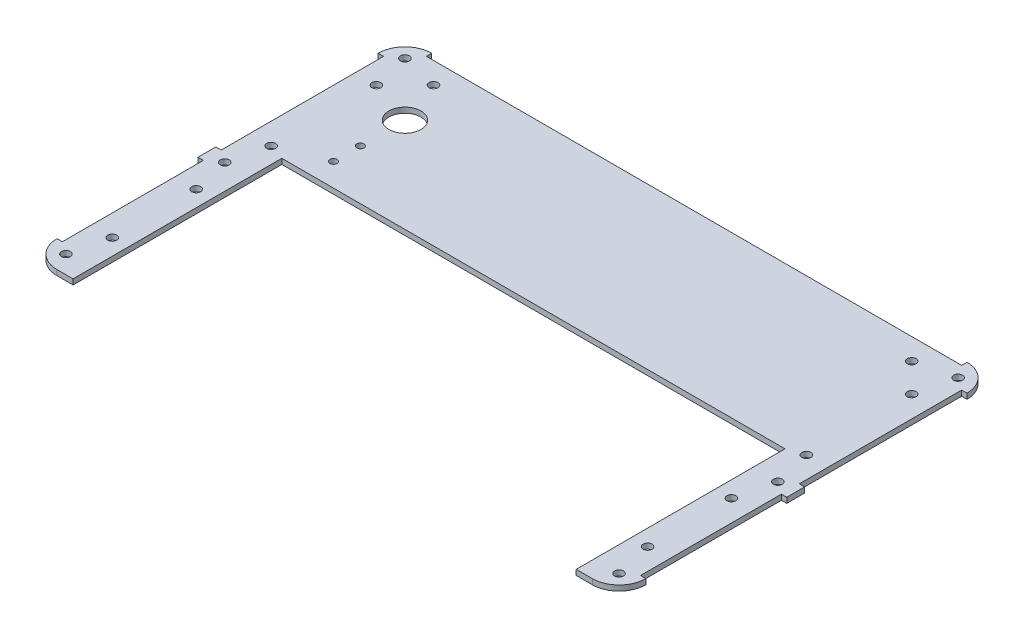
from build123d import *

# Parameters (mm, degrees)
ESQUISSE1_R      = 2.5
ESQUISSE1_R_2    = 9
ESQUISSE1_R_3    = 2
EXTRUSION1_DEPTH = 3
CONG_1_R         = 15
EXTRUSION2_REACH = 5
ESQUISSE2_W      = 300
ESQUISSE2_H      = 3
ESQUISSE2_W_2    = 3
ESQUISSE2_H_2    = 91
ESQUISSE2_H_3    = 79
EXTRUSION3_REACH = 5
ESQUISSE3_R      = 2.5


with BuildPart() as part:
    # Esquisse1 → Extrusion1 (new body)
    with BuildSketch(Plane(origin=(0, 0, 0), x_dir=(1, 0, 0), z_dir=(0, 1, 0))):
        Polygon((0, 0), (24, 0), (24, 117), (165, 117), (306, 117), (306, 0), (330, 0), (330, 210), (0, 210), align=None)
        with Locations((10, 200)):
            Circle(ESQUISSE1_R, mode=Mode.SUBTRACT)
        with Locations((320, 200)):
            Circle(ESQUISSE1_R, mode=Mode.SUBTRACT)
        with Locations((10, 99)):
            Circle(ESQUISSE1_R, mode=Mode.SUBTRACT)
        with Locations((320, 99)):
            Circle(ESQUISSE1_R, mode=Mode.SUBTRACT)
        with Locations((10, 10)):
            Circle(ESQUISSE1_R, mode=Mode.SUBTRACT)
        with Locations((320, 10)):
            Circle(ESQUISSE1_R, mode=Mode.SUBTRACT)
        with Locations((40, 170)):
            Circle(ESQUISSE1_R_2, mode=Mode.SUBTRACT)
        with Locations((40, 145)):
            Circle(ESQUISSE1_R_3, mode=Mode.SUBTRACT)
        with Locations((40, 130)):
            Circle(ESQUISSE1_R_3, mode=Mode.SUBTRACT)
    extrude(amount=EXTRUSION1_DEPTH)

    # Congé1
    cong_1_edges = [part.edges().sort_by_distance(p)[0] for p in [
        (0, 1.5, -210),
        (330, 1.5, -210),
        (330, 1.5, 0),
        (0, 1.5, 0),
    ]]
    fillet(cong_1_edges, radius=CONG_1_R)

    # Esquisse2 → Extrusion2 (cut, up to next)
    with BuildSketch(Plane(origin=(0, 3, 0), x_dir=(1, 0, 0), z_dir=(0, 1, 0)), mode=Mode.PRIVATE) as extrusion2_sk1:
        with Locations((165, 208.5)):
            Rectangle(ESQUISSE2_W, ESQUISSE2_H)
    extrusion2_tool1 = extrude(extrusion2_sk1.sketch, amount=-EXTRUSION2_REACH, mode=Mode.PRIVATE) & part.part
    add(extrusion2_tool1.solids().sort_by_distance((165, 3, -208.5))[0], mode=Mode.SUBTRACT)
    # Esquisse2 → Extrusion2 (cut, up to next)
    with BuildSketch(Plane(origin=(0, 3, 0), x_dir=(1, 0, 0), z_dir=(0, 1, 0)), mode=Mode.PRIVATE) as extrusion2_sk2:
        with Locations((1.5, 149.5)):
            Rectangle(ESQUISSE2_W_2, ESQUISSE2_H_2)
    extrusion2_tool2 = extrude(extrusion2_sk2.sketch, amount=-EXTRUSION2_REACH, mode=Mode.PRIVATE) & part.part
    add(extrusion2_tool2.solids().sort_by_distance((1.5, 3, -149.5))[0], mode=Mode.SUBTRACT)
    # Esquisse2 → Extrusion2 (cut, up to next)
    with BuildSketch(Plane(origin=(0, 3, 0), x_dir=(1, 0, 0), z_dir=(0, 1, 0)), mode=Mode.PRIVATE) as extrusion2_sk3:
        with Locations((1.5, 54.5)):
            Rectangle(ESQUISSE2_W_2, ESQUISSE2_H_3)
    extrusion2_tool3 = extrude(extrusion2_sk3.sketch, amount=-EXTRUSION2_REACH, mode=Mode.PRIVATE) & part.part
    add(extrusion2_tool3.solids().sort_by_distance((1.5, 3, -54.5))[0], mode=Mode.SUBTRACT)
    # Esquisse2 → Extrusion2 (cut, up to next)
    with BuildSketch(Plane(origin=(0, 3, 0), x_dir=(1, 0, 0), z_dir=(0, 1, 0)), mode=Mode.PRIVATE) as extrusion2_sk4:
        with Locations((328.5, 54.5)):
            Rectangle(ESQUISSE2_W_2, ESQUISSE2_H_3)
    extrusion2_tool4 = extrude(extrusion2_sk4.sketch, amount=-EXTRUSION2_REACH, mode=Mode.PRIVATE) & part.part
    add(extrusion2_tool4.solids().sort_by_distance((328.5, 3, -54.5))[0], mode=Mode.SUBTRACT)
    # Esquisse2 → Extrusion2 (cut, up to next)
    with BuildSketch(Plane(origin=(0, 3, 0), x_dir=(1, 0, 0), z_dir=(0, 1, 0)), mode=Mode.PRIVATE) as extrusion2_sk5:
        with Locations((328.5, 149.5)):
            Rectangle(ESQUISSE2_W_2, ESQUISSE2_H_2)
    extrusion2_tool5 = extrude(extrusion2_sk5.sketch, amount=-EXTRUSION2_REACH, mode=Mode.PRIVATE) & part.part
    add(extrusion2_tool5.solids().sort_by_distance((328.5, 3, -149.5))[0], mode=Mode.SUBTRACT)

    # Esquisse3 → Extrusion3 (cut, up to next)
    with BuildSketch(Plane(origin=(0, 3, 0), x_dir=(1, 0, 0), z_dir=(0, 1, 0)), mode=Mode.PRIVATE) as extrusion3_sk1:
        with Locations((31, 195)):
            Circle(ESQUISSE3_R)
    extrusion3_tool1 = extrude(extrusion3_sk1.sketch, amount=-EXTRUSION3_REACH, mode=Mode.PRIVATE) & part.part
    add(extrusion3_tool1.solids().sort_by_distance((31, 3, -195))[0], mode=Mode.SUBTRACT)
    # Esquisse3 → Extrusion3 (cut, up to next)
    with BuildSketch(Plane(origin=(0, 3, 0), x_dir=(1, 0, 0), z_dir=(0, 1, 0)), mode=Mode.PRIVATE) as extrusion3_sk2:
        with Locations((15, 179)):
            Circle(ESQUISSE3_R)
    extrusion3_tool2 = extrude(extrusion3_sk2.sketch, amount=-EXTRUSION3_REACH, mode=Mode.PRIVATE) & part.part
    add(extrusion3_tool2.solids().sort_by_distance((15, 3, -179))[0], mode=Mode.SUBTRACT)
    # Esquisse3 → Extrusion3 (cut, up to next)
    with BuildSketch(Plane(origin=(0, 3, 0), x_dir=(1, 0, 0), z_dir=(0, 1, 0)), mode=Mode.PRIVATE) as extrusion3_sk3:
        with Locations((15, 120)):
            Circle(ESQUISSE3_R)
    extrusion3_tool3 = extrude(extrusion3_sk3.sketch, amount=-EXTRUSION3_REACH, mode=Mode.PRIVATE) & part.part
    add(extrusion3_tool3.solids().sort_by_distance((15, 3, -120))[0], mode=Mode.SUBTRACT)
    # Esquisse3 → Extrusion3 (cut, up to next)
    with BuildSketch(Plane(origin=(0, 3, 0), x_dir=(1, 0, 0), z_dir=(0, 1, 0)), mode=Mode.PRIVATE) as extrusion3_sk4:
        with Locations((15, 78)):
            Circle(ESQUISSE3_R)
    extrusion3_tool4 = extrude(extrusion3_sk4.sketch, amount=-EXTRUSION3_REACH, mode=Mode.PRIVATE) & part.part
    add(extrusion3_tool4.solids().sort_by_distance((15, 3, -78))[0], mode=Mode.SUBTRACT)
    # Esquisse3 → Extrusion3 (cut, up to next)
    with BuildSketch(Plane(origin=(0, 3, 0), x_dir=(1, 0, 0), z_dir=(0, 1, 0)), mode=Mode.PRIVATE) as extrusion3_sk5:
        with Locations((15, 31)):
            Circle(ESQUISSE3_R)
    extrusion3_tool5 = extrude(extrusion3_sk5.sketch, amount=-EXTRUSION3_REACH, mode=Mode.PRIVATE) & part.part
    add(extrusion3_tool5.solids().sort_by_distance((15, 3, -31))[0], mode=Mode.SUBTRACT)
    # Esquisse3 → Extrusion3 (cut, up to next)
    with BuildSketch(Plane(origin=(0, 3, 0), x_dir=(1, 0, 0), z_dir=(0, 1, 0)), mode=Mode.PRIVATE) as extrusion3_sk6:
        with Locations((299, 195)):
            Circle(ESQUISSE3_R)
    extrusion3_tool6 = extrude(extrusion3_sk6.sketch, amount=-EXTRUSION3_REACH, mode=Mode.PRIVATE) & part.part
    add(extrusion3_tool6.solids().sort_by_distance((299, 3, -195))[0], mode=Mode.SUBTRACT)
    # Esquisse3 → Extrusion3 (cut, up to next)
    with BuildSketch(Plane(origin=(0, 3, 0), x_dir=(1, 0, 0), z_dir=(0, 1, 0)), mode=Mode.PRIVATE) as extrusion3_sk7:
        with Locations((315, 179)):
            Circle(ESQUISSE3_R)
    extrusion3_tool7 = extrude(extrusion3_sk7.sketch, amount=-EXTRUSION3_REACH, mode=Mode.PRIVATE) & part.part
    add(extrusion3_tool7.solids().sort_by_distance((315, 3, -179))[0], mode=Mode.SUBTRACT)
    # Esquisse3 → Extrusion3 (cut, up to next)
    with BuildSketch(Plane(origin=(0, 3, 0), x_dir=(1, 0, 0), z_dir=(0, 1, 0)), mode=Mode.PRIVATE) as extrusion3_sk8:
        with Locations((315, 120)):
            Circle(ESQUISSE3_R)
    extrusion3_tool8 = extrude(extrusion3_sk8.sketch, amount=-EXTRUSION3_REACH, mode=Mode.PRIVATE) & part.part
    add(extrusion3_tool8.solids().sort_by_distance((315, 3, -120))[0], mode=Mode.SUBTRACT)
    # Esquisse3 → Extrusion3 (cut, up to next)
    with BuildSketch(Plane(origin=(0, 3, 0), x_dir=(1, 0, 0), z_dir=(0, 1, 0)), mode=Mode.PRIVATE) as extrusion3_sk9:
        with Locations((315, 78)):
            Circle(ESQUISSE3_R)
    extrusion3_tool9 = extrude(extrusion3_sk9.sketch, amount=-EXTRUSION3_REACH, mode=Mode.PRIVATE) & part.part
    add(extrusion3_tool9.solids().sort_by_distance((315, 3, -78))[0], mode=Mode.SUBTRACT)
    # Esquisse3 → Extrusion3 (cut, up to next)
    with BuildSketch(Plane(origin=(0, 3, 0), x_dir=(1, 0, 0), z_dir=(0, 1, 0)), mode=Mode.PRIVATE) as extrusion3_sk10:
        with Locations((315, 31)):
            Circle(ESQUISSE3_R)
    extrusion3_tool10 = extrude(extrusion3_sk10.sketch, amount=-EXTRUSION3_REACH, mode=Mode.PRIVATE) & part.part
    add(extrusion3_tool10.solids().sort_by_distance((315, 3, -31))[0], mode=Mode.SUBTRACT)


solid = part.part
